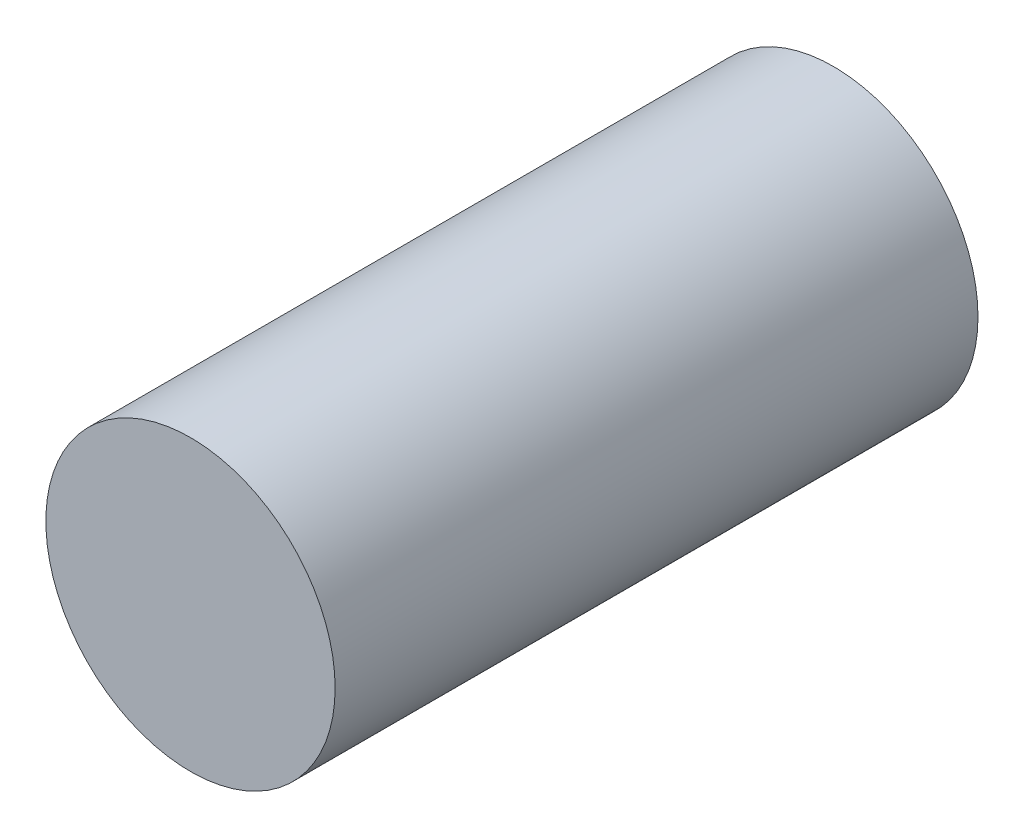
from build123d import *

# Parameters (mm, degrees)
SKETCH1_R                = 4.5
BOSS_EXTRUDE1_DEPTH      = 14
BOSS_EXTRUDE1_DEPTH_BACK = 6


with BuildPart() as part:
    # Sketch1 → Boss-Extrude1 (new body, two sides)
    with BuildSketch(Plane.XY) as boss_extrude1_sk:
        with Locations((0, 43.138377069)):
            Circle(SKETCH1_R)
    extrude(amount=BOSS_EXTRUDE1_DEPTH)
    extrude(boss_extrude1_sk.sketch, amount=-BOSS_EXTRUDE1_DEPTH_BACK)


solid = part.part
